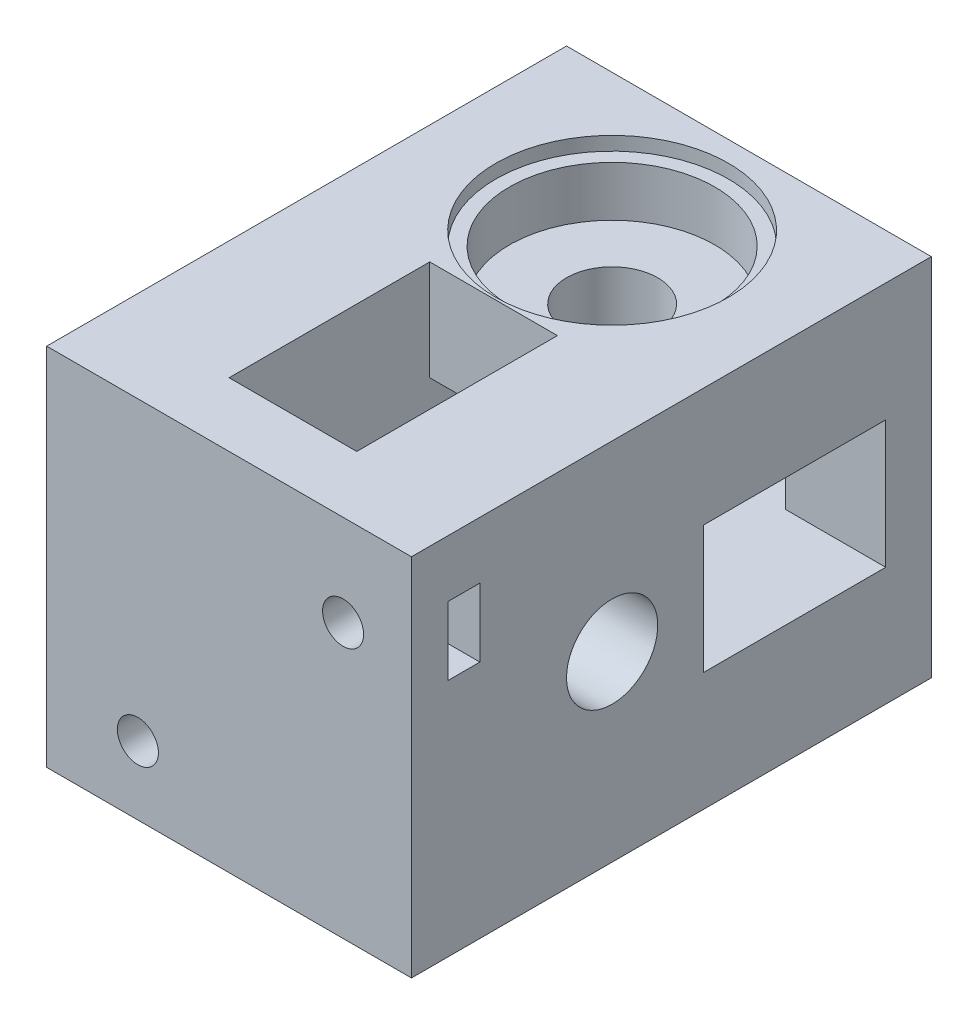
from build123d import *

# Parameters (mm, degrees)
ESQUISSE1_W              = 40
ESQUISSE1_H              = 40
BOSS_EXTRU_1_DEPTH       = 50
ESQUISSE2_R              = 5
ENL_V_MAT_EXTRU_1_DEPTH  = 41
ESQUISSE3_R              = 5
ENL_V_MAT_EXTRU_2_DEPTH  = 41
ESQUISSE4_W              = 22
ESQUISSE4_H              = 14
ENL_V_MAT_EXTRU_3_DEPTH  = 29
ESQUISSE5_W              = 14
ESQUISSE5_H              = 20
ENL_V_MAT_EXTRU_4_DEPTH  = 29
ESQUISSE6_W              = 20
ESQUISSE6_H              = 14
ENL_V_MAT_EXTRU_5_DEPTH  = 24
ESQUISSE7_W              = 14
ESQUISSE7_H              = 22
ENL_V_MAT_EXTRU_6_DEPTH  = 24
ESQUISSE10_R             = 11.25
ENL_V_MAT_EXTRU_9_DEPTH  = 7
ESQUISSE11_R             = 12.75
ENL_V_MAT_EXTRU_10_DEPTH = 1.5
ESQUISSE14_R             = 11.25
ENL_V_MAT_EXTRU_11_DEPTH = 7
ESQUISSE15_R             = 12.75
ENL_V_MAT_EXTRU_12_DEPTH = 1.5
ESQUISSE16_W             = 40
ESQUISSE16_H             = 40
BOSS_EXTRU_2_DEPTH       = 7
ESQUISSE17_R             = 2.25
ENL_V_MAT_EXTRU_13_DEPTH = 15
ESQUISSE18_W             = 7
ESQUISSE18_H             = 3
ENL_V_MAT_EXTRU_14_DEPTH = 12
ESQUISSE19_W             = 3.5
ESQUISSE19_H             = 7.5
ENL_V_MAT_EXTRU_15_DEPTH = 12


with BuildPart() as part:
    # Esquisse1 → Boss.-Extru.1 (new body)
    with BuildSketch(Plane.XY):
        with Locations((-20, 20)):
            Rectangle(ESQUISSE1_W, ESQUISSE1_H)
    extrude(amount=BOSS_EXTRU_1_DEPTH)

    # Esquisse2 → Enlèv. mat.-Extru.1 (cut, through all)
    with BuildSketch(Plane(origin=(0, 40, 0), x_dir=(1, 0, 0), z_dir=(0, 1, 0))):
        with Locations(Location((-20, -15, 0), (0, 0, 270))):  # turned: the seam where the file's is
            Circle(ESQUISSE2_R)
    extrude(amount=-ENL_V_MAT_EXTRU_1_DEPTH, mode=Mode.SUBTRACT)

    # Esquisse3 → Enlèv. mat.-Extru.2 (cut, through all)
    with BuildSketch(Plane.ZY.offset(40)):
        with Locations((35, 20)):
            Circle(ESQUISSE3_R)
    extrude(amount=-ENL_V_MAT_EXTRU_2_DEPTH, mode=Mode.SUBTRACT)

    # Esquisse4 → Enlèv. mat.-Extru.3 (cut)
    with BuildSketch(Plane.ZY.offset(40)):
        with Locations((11, 20)):
            Rectangle(ESQUISSE4_W, ESQUISSE4_H)
    extrude(amount=-ENL_V_MAT_EXTRU_3_DEPTH, mode=Mode.SUBTRACT)

    # Esquisse5 → Enlèv. mat.-Extru.4 (cut)
    with BuildSketch(Plane.XZ):
        with Locations((-20, 35)):
            Rectangle(ESQUISSE5_W, ESQUISSE5_H)
    extrude(amount=-ENL_V_MAT_EXTRU_4_DEPTH, mode=Mode.SUBTRACT)

    # Esquisse6 → Enlèv. mat.-Extru.5 (cut)
    with BuildSketch(Plane(origin=(0, 0, 0), x_dir=(0, 0, -1), z_dir=(1, 0, 0))):
        with Locations((-15, 20)):
            Rectangle(ESQUISSE6_W, ESQUISSE6_H)
    extrude(amount=-ENL_V_MAT_EXTRU_5_DEPTH, mode=Mode.SUBTRACT)

    # Esquisse7 → Enlèv. mat.-Extru.6 (cut)
    with BuildSketch(Plane(origin=(0, 40, 0), x_dir=(1, 0, 0), z_dir=(0, 1, 0))):
        with Locations((-20, -39)):
            Rectangle(ESQUISSE7_W, ESQUISSE7_H)
    extrude(amount=-ENL_V_MAT_EXTRU_6_DEPTH, mode=Mode.SUBTRACT)

    # Esquisse10 → Enlèv. mat.-Extru.9 (cut)
    with BuildSketch(Plane(origin=(0, 40, 0), x_dir=(1, 0, 0), z_dir=(0, 1, 0))):
        with Locations(Location((-20, -15, 0), (0, 0, 270))):  # turned: the seam where the file's is
            Circle(ESQUISSE10_R)
    extrude(amount=-ENL_V_MAT_EXTRU_9_DEPTH, mode=Mode.SUBTRACT)

    # Esquisse11 → Enlèv. mat.-Extru.10 (cut)
    with BuildSketch(Plane(origin=(0, 40, 0), x_dir=(1, 0, 0), z_dir=(0, 1, 0))):
        with Locations(Location((-20, -15, 0), (0, 0, 270))):  # turned: the seam where the file's is
            Circle(ESQUISSE11_R)
    extrude(amount=-ENL_V_MAT_EXTRU_10_DEPTH, mode=Mode.SUBTRACT)

    # Esquisse14 → Enlèv. mat.-Extru.11 (cut)
    with BuildSketch(Plane.ZY.offset(40)):
        with Locations((35, 20)):
            Circle(ESQUISSE14_R)
    extrude(amount=-ENL_V_MAT_EXTRU_11_DEPTH, mode=Mode.SUBTRACT)

    # Esquisse15 → Enlèv. mat.-Extru.12 (cut)
    with BuildSketch(Plane.ZY.offset(40)):
        with Locations((35, 20)):
            Circle(ESQUISSE15_R)
    extrude(amount=-ENL_V_MAT_EXTRU_12_DEPTH, mode=Mode.SUBTRACT)

    # Esquisse16 → Boss.-Extru.2 (add)
    with BuildSketch(Plane.XY.offset(50)):
        with Locations((-20, 20)):
            Rectangle(ESQUISSE16_W, ESQUISSE16_H)
    extrude(amount=BOSS_EXTRU_2_DEPTH)

    # Esquisse17 → Enlèv. mat.-Extru.13 (cut)
    with BuildSketch(Plane.XY.offset(57)):
        with Locations((-30, 7.5)):
            Circle(ESQUISSE17_R)
        with Locations((-7.5, 30)):
            Circle(ESQUISSE17_R)
    extrude(amount=-ENL_V_MAT_EXTRU_13_DEPTH, mode=Mode.SUBTRACT)

    # Esquisse18 → Enlèv. mat.-Extru.14 (cut)
    with BuildSketch(Plane.XZ):
        with Locations((-30, 51.5)):
            Rectangle(ESQUISSE18_W, ESQUISSE18_H)
    extrude(amount=-ENL_V_MAT_EXTRU_14_DEPTH, mode=Mode.SUBTRACT)

    # Esquisse19 → Enlèv. mat.-Extru.15 (cut)
    with BuildSketch(Plane(origin=(0, 0, 0), x_dir=(0, 0, -1), z_dir=(1, 0, 0))):
        with Locations((-51.25, 30)):
            Rectangle(ESQUISSE19_W, ESQUISSE19_H)
    extrude(amount=-ENL_V_MAT_EXTRU_15_DEPTH, mode=Mode.SUBTRACT)


solid = part.part
